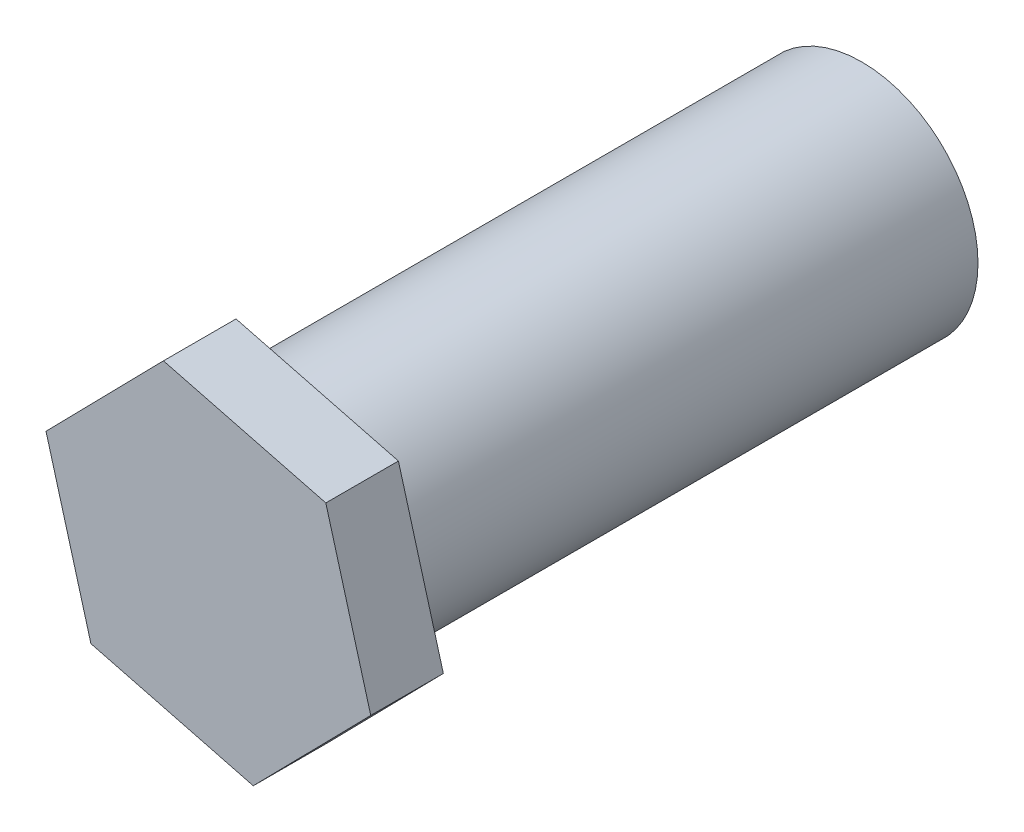
from build123d import *

# Parameters (mm, degrees)
ESQUISSE1_R        = 40
BOSS_EXTRU_1_DEPTH = 200
BOSS_EXTRU_2_DEPTH = 25


with BuildPart() as part:
    # Esquisse1 → Boss.-Extru.1 (new body)
    with BuildSketch(Plane.XY):
        Circle(ESQUISSE1_R)
    extrude(amount=BOSS_EXTRU_1_DEPTH)

    # Esquisse2 → Boss.-Extru.2 (add)
    with BuildSketch(Plane.XY.offset(200)):
        Polygon((55.906189806, -14.416354416), (40.438024058, 41.208003393), (-15.468165749, 55.624357809), (-55.906189806, 14.416354416), (-40.438024058, -41.208003393), (15.468165749, -55.624357809), align=None)
    extrude(amount=BOSS_EXTRU_2_DEPTH)


solid = part.part
